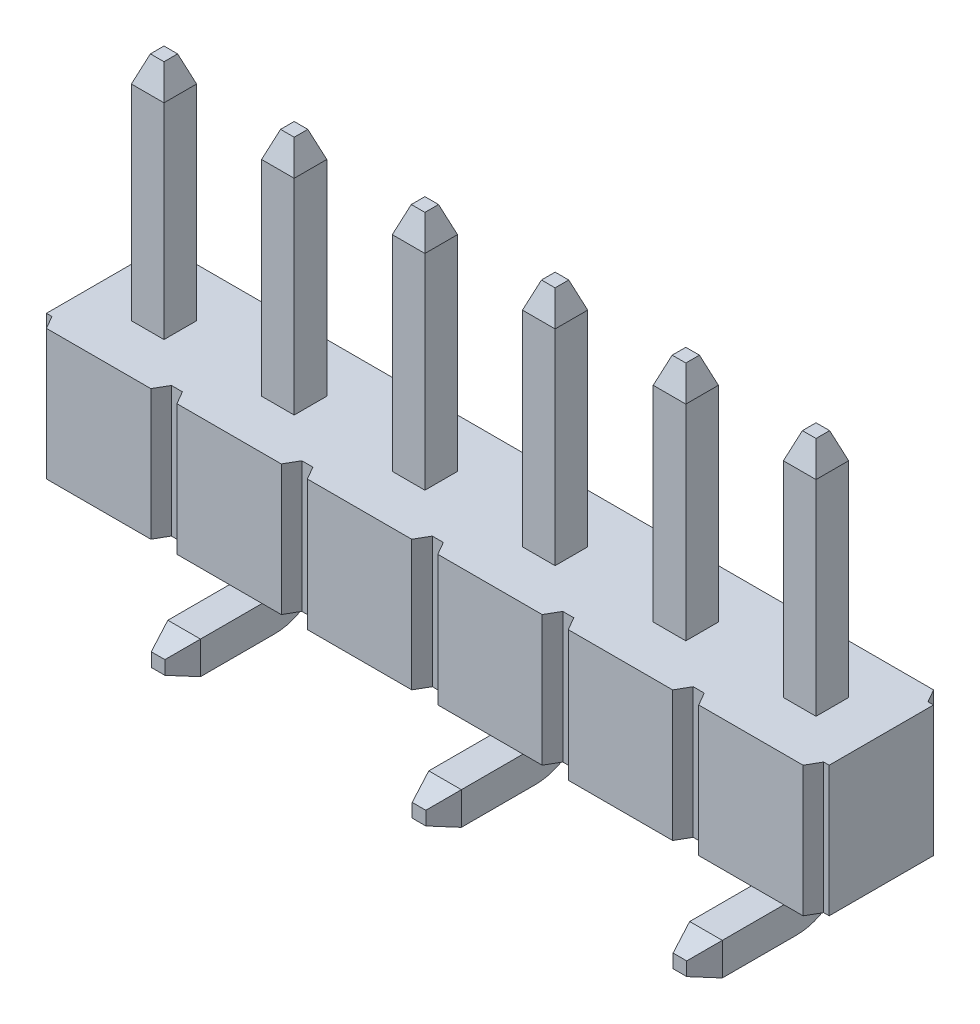
from build123d import *

# Parameters (mm, degrees)
SKETCH1_W                            = 15.24
SKETCH1_H                            = 2.54
BASE_EXTRUDE_DEPTH                   = 1.27
PIN_DEPTH                            = 0.3175
PIN_CHAMFER_SIZE2                    = 0.184896879
PIN_CHAMFER_SIZE                     = 0.508
PIN_PATTERN_COUNT                    = 3
PIN_PATTERN_PITCH                    = 5.08
PIN_CHAMFER_OF_PIN_PATTERN_SIZE2     = 0.184896879
PIN_CHAMFER_OF_PIN_PATTERN_SIZE      = 0.508
PIN_2_DEPTH                          = 0.3175
PIN_2_CHAMFER_SIZE2                  = 0.184896879
PIN_2_CHAMFER_SIZE                   = 0.508
PIN_2_PATTERN_COUNT                  = 3
PIN_2_PATTERN_PITCH                  = 5.08
PIN_2_CHAMFER_OF_PIN_2_PATTERN_SIZE2 = 0.184896879
PIN_2_CHAMFER_OF_PIN_2_PATTERN_SIZE  = 0.508
SV_CUT_DEPTH                         = 4.5
SV_CUT_PATTERN_COUNT                 = 5
SV_CUT_PATTERN_PITCH                 = 2.54
LPATTERN1_COUNT                      = 3
LPATTERN1_PITCH                      = 2.54


with BuildPart() as part:
    # Sketch1 → Base Extrude (new body, symmetric)
    with BuildSketch(Plane(origin=(0, 0, 0), x_dir=(1, 0, 0), z_dir=(0, 1, 0))):
        with Locations((6.35, 0)):
            Rectangle(SKETCH1_W, SKETCH1_H)
    extrude(amount=BASE_EXTRUDE_DEPTH, both=True)

    # Sketch8 → Pin (add, symmetric)
    with BuildSketch(Plane(origin=(0, 0, 0), x_dir=(0, 0, -1), z_dir=(1, 0, 0))):
        with BuildLine():
            Line((0.32004, -1.087), (0.32004, 5.262))
            Line((0.32004, 5.262), (0.135143121, 5.77))
            Line((0.135143121, 5.77), (-0.130063121, 5.77))
            Line((-0.130063121, 5.77), (-0.31496, 5.262))
            Line((-0.31496, 5.262), (-0.31496, -1.214))
            ThreePointArc((-0.31496, -1.214), (-0.01738049, -1.93242049), (0.70104, -2.23))
            Line((0.70104, -2.23), (2.142, -2.23))
            Line((2.142, -2.23), (2.65, -2.045103121))
            Line((2.65, -2.045103121), (2.65, -1.779896879))
            Line((2.65, -1.779896879), (2.142, -1.595))
            Line((2.142, -1.595), (0.82804, -1.595))
            ThreePointArc((0.82804, -1.595), (0.468829755, -1.446210245), (0.32004, -1.087))
        make_face()
    pin = extrude(amount=PIN_DEPTH, both=True)

    # Pin Chamfer
    pin_chamfer_edges = [part.edges().sort_by_distance(p)[0] for p in [
        (0.3175, -1.9125, -2.65),
        (-0.3175, 5.77, -0.00254),
        (-0.3175, -1.9125, -2.65),
        (0.3175, 5.77, -0.00254),
    ]]
    chamfer(pin_chamfer_edges, length=PIN_CHAMFER_SIZE, length2=PIN_CHAMFER_SIZE2)

    # Pin Pattern: Pin ×3
    with Locations(*[(i * PIN_PATTERN_PITCH, 0, 0) for i in range(1, PIN_PATTERN_COUNT)]):
        add(pin)

    # Pin Chamfer of Pin Pattern
    pin_chamfer_of_pin_pattern_edges = [part.edges().sort_by_distance(p)[0] for p in [
        (5.3975, -1.9125, -2.65),
        (4.7625, 5.77, -0.00254),
        (4.7625, -1.9125, -2.65),
        (5.3975, 5.77, -0.00254),
        (10.4775, -1.9125, -2.65),
        (9.8425, 5.77, -0.00254),
        (9.8425, -1.9125, -2.65),
        (10.4775, 5.77, -0.00254),
    ]]
    chamfer(pin_chamfer_of_pin_pattern_edges, length=PIN_CHAMFER_OF_PIN_PATTERN_SIZE, length2=PIN_CHAMFER_OF_PIN_PATTERN_SIZE2)

    # Sketch9 → Pin 2 (add, symmetric)
    with BuildSketch(Plane(origin=(2.54, 0, 0), x_dir=(0, 0, -1), z_dir=(1, 0, 0))):
        with BuildLine():
            Line((-0.32004, -1.087), (-0.32004, 5.262))
            Line((-0.32004, 5.262), (-0.135143121, 5.77))
            Line((-0.135143121, 5.77), (0.130063121, 5.77))
            Line((0.130063121, 5.77), (0.31496, 5.262))
            Line((0.31496, 5.262), (0.31496, -1.214))
            ThreePointArc((0.31496, -1.214), (0.01738049, -1.93242049), (-0.70104, -2.23))
            Line((-0.70104, -2.23), (-2.14454, -2.23))
            Line((-2.14454, -2.23), (-2.65254, -2.045103121))
            Line((-2.65254, -2.045103121), (-2.65254, -1.779896879))
            Line((-2.65254, -1.779896879), (-2.14454, -1.595))
            Line((-2.14454, -1.595), (-0.82804, -1.595))
            ThreePointArc((-0.82804, -1.595), (-0.468829755, -1.446210245), (-0.32004, -1.087))
        make_face()
    pin_2 = extrude(amount=PIN_2_DEPTH, both=True)

    # Pin 2 Chamfer
    pin_2_chamfer_edges = [part.edges().sort_by_distance(p)[0] for p in [
        (2.8575, -1.9125, 2.65254),
        (2.2225, -1.9125, 2.65254),
        (2.2225, 5.77, 0.00254),
        (2.8575, 5.77, 0.00254),
    ]]
    chamfer(pin_2_chamfer_edges, length=PIN_2_CHAMFER_SIZE, length2=PIN_2_CHAMFER_SIZE2)

    # Pin 2 Pattern: Pin 2 ×3
    with Locations(*[(i * PIN_2_PATTERN_PITCH, 0, 0) for i in range(1, PIN_2_PATTERN_COUNT)]):
        add(pin_2)

    # Pin 2 Chamfer of Pin 2 Pattern
    pin_2_chamfer_of_pin_2_pattern_edges = [part.edges().sort_by_distance(p)[0] for p in [
        (7.9375, -1.9125, 2.65254),
        (7.3025, -1.9125, 2.65254),
        (7.3025, 5.77, 0.00254),
        (7.9375, 5.77, 0.00254),
        (13.0175, -1.9125, 2.65254),
        (12.3825, -1.9125, 2.65254),
        (12.3825, 5.77, 0.00254),
        (13.0175, 5.77, 0.00254),
    ]]
    chamfer(pin_2_chamfer_of_pin_2_pattern_edges, length=PIN_2_CHAMFER_OF_PIN_2_PATTERN_SIZE, length2=PIN_2_CHAMFER_OF_PIN_2_PATTERN_SIZE2)

    # Sketch15 → SV Cut (cut, through all)
    with BuildSketch(Plane(origin=(0, 1.27, 0), x_dir=(-1, 0, 0), z_dir=(0, 1, 0))):
        Polygon((-3.556, 1.27), (-3.702646976, 1.016), (-3.917353024, 1.016), (-4.064, 1.27), align=None)
        Polygon((-4.064, -1.27), (-3.917353024, -1.016), (-3.702646976, -1.016), (-3.556, -1.27), align=None)
    sv_cut = extrude(amount=-SV_CUT_DEPTH, mode=Mode.SUBTRACT)

    # SV Cut Pattern: SV Cut ×5
    with Locations(*[(i * SV_CUT_PATTERN_PITCH, 0, 0) for i in range(1, SV_CUT_PATTERN_COUNT)]):
        add(sv_cut, mode=Mode.SUBTRACT)

    # LPattern1: SV Cut ×3
    with Locations(*[(-i * LPATTERN1_PITCH, 0, 0) for i in range(1, LPATTERN1_COUNT)]):
        add(sv_cut, mode=Mode.SUBTRACT)


solid = part.part
